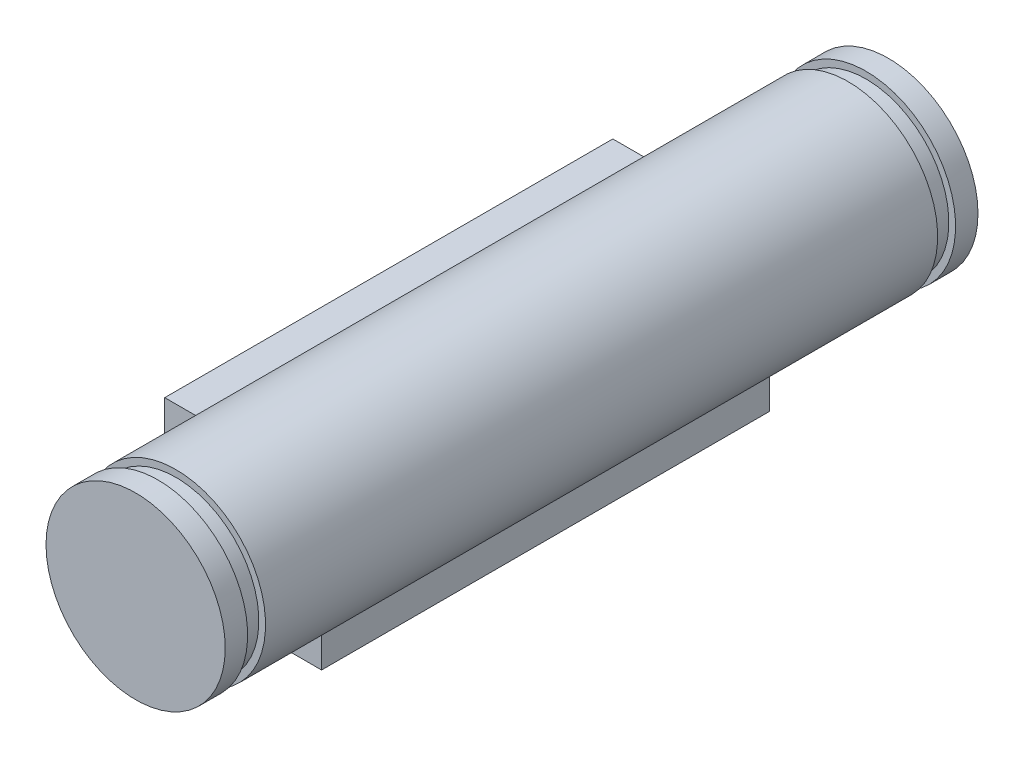
from build123d import *

# Parameters (mm, degrees)
SKETCH_1_R          = 4
EXTRUDE_1_DEPTH     = 16.8
SKETCH_2_W          = 0.8
SKETCH_2_H          = 0.3
EXTRUDE_2_DEPTH     = 10
CUT_EXTRUDE_1_DEPTH = 20


with BuildPart() as part:
    # 草图1 → 凸台-拉伸1 (new body, symmetric)
    with BuildSketch(Plane.XY):
        Circle(SKETCH_1_R)
    extrude(amount=EXTRUDE_1_DEPTH, both=True)

    # 草图2 → 切除-旋转1 (revolve, cut)
    with BuildSketch(Plane(origin=(0, 0, 0), x_dir=(0, 0, -1), z_dir=(1, 0, 0))):
        with Locations((-15.4, 3.85)):
            Rectangle(SKETCH_2_W, SKETCH_2_H)
        with Locations((15.4, 3.85)):
            Rectangle(SKETCH_2_W, SKETCH_2_H)
    revolve(axis=Axis((0, 0, -18.8), (0, 0, 1)), mode=Mode.SUBTRACT)

    # 草图3 → 凸台-拉伸2 (add, symmetric)
    with BuildSketch(Plane(origin=(0, 0, 0), x_dir=(-1, 0, 0), z_dir=(0, 0, 1))):
        with BuildLine():
            Line((5.5, 1.5), (3.708099, 1.5))
            ThreePointArc((3.708099, 1.5), (2.839864, 2.816943), (1.53, 3.695822))
            Line((1.53, 3.695822), (1.53, 5.5))
            Line((1.53, 5.5), (-1.5, 5.5))
            Line((-1.5, 5.5), (-1.5, 3.708099))
            ThreePointArc((-1.5, 3.708099), (-2.839864, -2.816943), (3.695822, -1.53))
            Line((3.695822, -1.53), (5.5, -1.53))
            Line((5.5, -1.53), (5.5, 1.5))
        make_face()
    extrude(amount=EXTRUDE_2_DEPTH, both=True)

    # 草图4 → 切除-拉伸1 (cut)
    with BuildSketch(Plane(origin=(0, 0, -16.8), x_dir=(-1, 0, 0), z_dir=(0, 0, -1))):
        with BuildLine():
            Line((1, -1.118034), (1, 1.118034))
            ThreePointArc((1, 1.118034), (-1.5, 0), (1, -1.118034))
        make_face()
    extrude(amount=-CUT_EXTRUDE_1_DEPTH, mode=Mode.SUBTRACT)


solid = part.part
